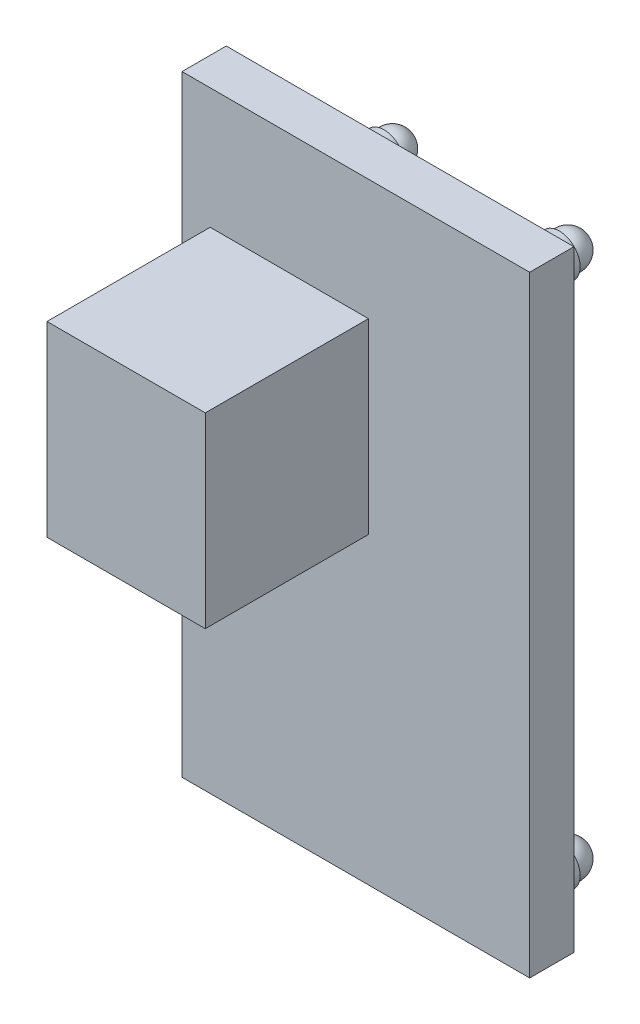
from build123d import *

# Parameters (mm, degrees)
BOSS_EXTRUDE1_START = 2
SKETCH1_W           = 12.57
SKETCH1_H           = 22.1
BOSS_EXTRUDE1_DEPTH = 1.6
SKETCH2_W           = 5.723607812
SKETCH2_H           = 6.758728373
BOSS_EXTRUDE2_DEPTH = 5.9
SKETCH3_R           = 0.75
BOSS_EXTRUDE3_DEPTH = 1


with BuildPart() as part:
    # Sketch1 → Boss-Extrude1 (new body)
    with BuildSketch(Plane.XY.offset(BOSS_EXTRUDE1_START)):
        Rectangle(SKETCH1_W, SKETCH1_H)
    extrude(amount=BOSS_EXTRUDE1_DEPTH)

    # Sketch2 → Boss-Extrude2 (add)
    with BuildSketch(Plane.XY.offset(3.6)):
        with Locations((-2.40513307, 3.303252381)):
            Rectangle(SKETCH2_W, SKETCH2_H)
    extrude(amount=BOSS_EXTRUDE2_DEPTH)

    # Sketch3 → Boss-Extrude3 (add)
    with BuildSketch(Plane(origin=(0, 0, 2), x_dir=(-1, 0, 0), z_dir=(0, 0, -1))):
        with Locations((-4.76, 9.53)):
            Circle(SKETCH3_R)
        with Locations((-4.76, -9.53)):
            Circle(SKETCH3_R)
        with Locations((4.76, -9.53)):
            Circle(SKETCH3_R)
        with Locations((1.58, 9.53)):
            Circle(SKETCH3_R)
    extrude(amount=BOSS_EXTRUDE3_DEPTH)


with BuildPart() as body_2:
    # Sketch4 → Revolve1 (revolve)
    with BuildSketch(Plane(origin=(0, 9.53, 0), x_dir=(1, 0, 0), z_dir=(0, 1, 0))):
        with BuildLine():
            Line((4.76, -1.35), (4.76, -0.05))
            ThreePointArc((4.76, -0.05), (4.11, -0.7), (4.76, -1.35))
        make_face()
    revolve1 = revolve(axis=Axis((4.76, 9.53, 1.35), (0, 0, -1)))


with BuildPart() as part_1:
    add(part.part)

    # Sketch-Pattern2: Revolve1 at 3 more places
    with Locations((-6.34, 0, 0), (0, -19.06, 0), (-9.52, -19.06, 0)):
        add(revolve1)


solid = Compound([body_2.part, part_1.part])
